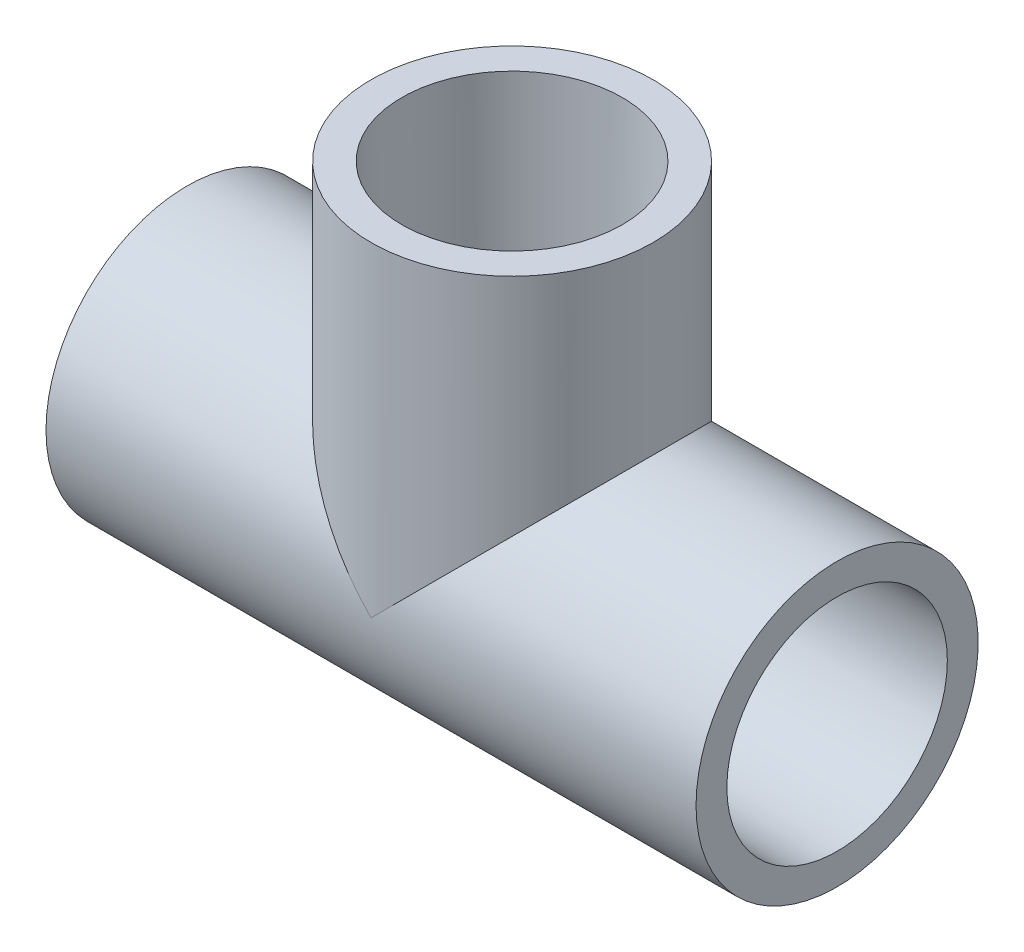
from build123d import *

# Parameters (mm, degrees)
SKETCH4_R           = 13.7795
BOSS_EXTRUDE1_DEPTH = 25.4
SKETCH5_R           = 13.7795
BOSS_EXTRUDE2_DEPTH = 12.7


with BuildPart() as part:
    # Sketch1 → Revolve1 (revolve)
    with BuildSketch(Plane.XY):
        Polygon((-31.75, -13.7795), (-12.7, -13.7795), (-12.7, -10.6172), (-31.75, -10.7696), align=None)
        Polygon((31.75, -10.7696), (12.7, -10.6172), (12.7, -13.7795), (31.75, -13.7795), align=None)
    revolve(axis=Axis((-31.75, 0, 0), (1, 0, 0)))



with BuildPart() as body_2:
    # Sketch2 → Revolve2 (revolve)
    with BuildSketch(Plane.XY):
        Polygon((10.7696, 31.75), (10.6172, 12.7), (13.7795, 12.7), (13.7795, 31.75), align=None)
    revolve(axis=Axis((0, 0, 0), (0, 1, 0)))


with BuildPart() as part_1:
    add(part.part)

    add(body_2.part)  # Boss-Extrude1 merges body 2
    # Sketch4 → Boss-Extrude1 (add)
    with BuildSketch(Plane(origin=(-12.7, 0, 0), x_dir=(0, 0, -1), z_dir=(1, 0, 0))):
        Circle(SKETCH4_R)
    extrude(amount=BOSS_EXTRUDE1_DEPTH)

    # Sketch5 → Boss-Extrude2 (add)
    with BuildSketch(Plane.XZ.offset(-12.7)):
        Circle(SKETCH5_R)
    extrude(amount=BOSS_EXTRUDE2_DEPTH)

    # Sketch6 → Cut-Revolve1 (revolve, cut)
    with BuildSketch(Plane.XY):
        Polygon((-31.75, -10.7696), (-12.7, -10.6172), (-12.7, -7.8994), (12.7, -7.8994), (12.7, -10.6172), (31.75, -10.7696), (31.75, 0), (-31.75, 0), align=None)
    revolve(axis=Axis((31.75, 0, 0), (-1, 0, 0)), mode=Mode.SUBTRACT)

    # Sketch7 → Cut-Revolve2 (revolve, cut)
    with BuildSketch(Plane.XY):
        Polygon((10.7696, 31.75), (10.6172, 12.7), (7.8994, 12.7), (7.8994, 0), (0, 0), (0, 31.75), align=None)
    revolve(axis=Axis((0, 0, 0), (0, 1, 0)), mode=Mode.SUBTRACT)


solid = part_1.part
